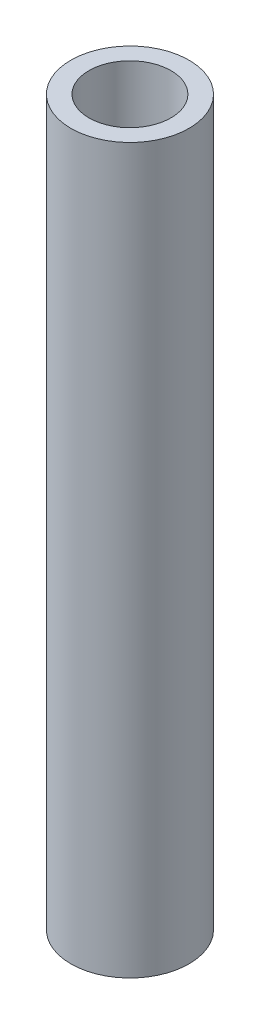
from build123d import *

# Parameters (mm, degrees)
SKETCH1_R           = 3.1115
SKETCH1_R_2         = 2.159
BOSS_EXTRUDE1_DEPTH = 19.05


with BuildPart() as part:
    # Sketch1 → Boss-Extrude1 (new body, symmetric)
    with BuildSketch(Plane(origin=(0, 0, 0), x_dir=(1, 0, 0), z_dir=(0, 1, 0))):
        Circle(SKETCH1_R)
        Circle(SKETCH1_R_2, mode=Mode.SUBTRACT)
    extrude(amount=BOSS_EXTRUDE1_DEPTH, both=True)


solid = part.part
